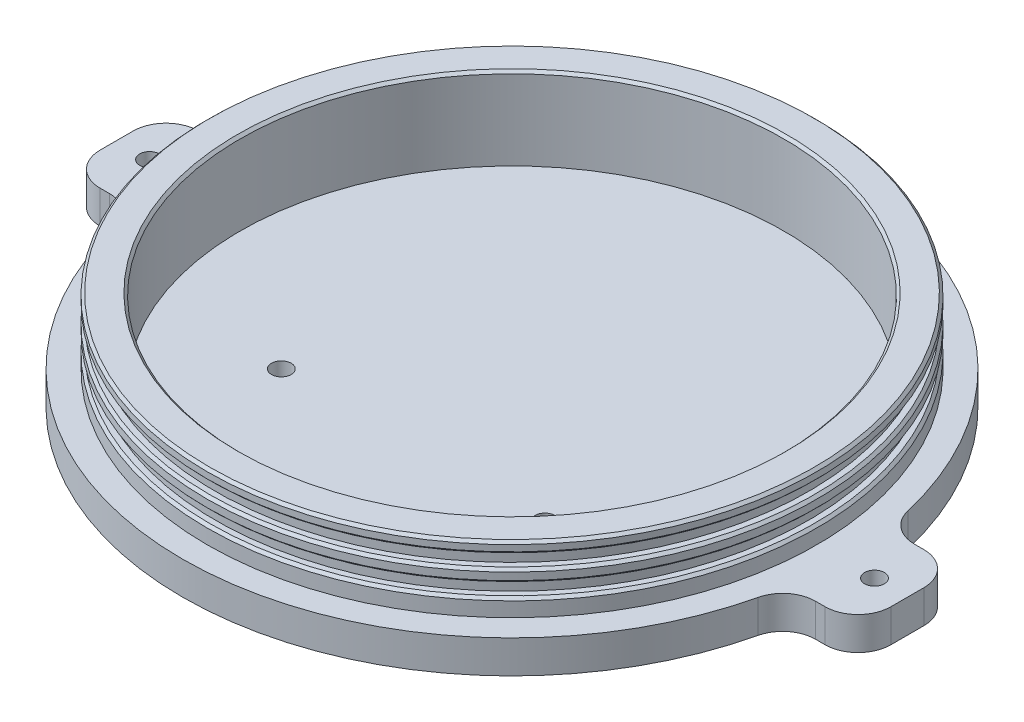
from build123d import *

# Parameters (mm, degrees)
SKETCH1_R                 = 63.5
EXTRUDE1_DEPTH            = 6.35
SKETCH2_R                 = 58.7375
SKETCH2_R_2               = 52.3875
EXTRUDE2_DEPTH            = 12.7
SKETCH3_W                 = 1.5875
SKETCH3_H                 = 2.38125
CHAMFER1_SIZE             = 0.5
EXTRUDE3_DEPTH            = 6.35
F_6_CLEARANCE_HOLE1_D     = 3.7973
F_6_CLEARANCE_HOLE1_DEPTH = 330.2
F_6_CLEARANCE_HOLE1_TIP   = 1.140824014
FILLET1_R                 = 6.35
F_6_CLEARANCE_HOLE2_D     = 3.7973
F_6_CLEARANCE_HOLE2_DEPTH = 25.4
F_6_CLEARANCE_HOLE2_TIP   = 1.140824014
SKETCH8_R                 = 52.3875
CUT_EXTRUDE1_DEPTH        = 3.175


with BuildPart() as part:
    # Sketch1 → Extrude1 (new body)
    with BuildSketch(Plane(origin=(0, 0, 0), x_dir=(1, 0, 0), z_dir=(0, 1, 0))):
        Circle(SKETCH1_R)
    extrude(amount=EXTRUDE1_DEPTH)

    # Sketch2 → Extrude2 (add)
    with BuildSketch(Plane(origin=(0, 6.35, 0), x_dir=(-1, 0, 0), z_dir=(0, 1, 0))):
        Circle(SKETCH2_R)
        Circle(SKETCH2_R_2, mode=Mode.SUBTRACT)
    extrude(amount=EXTRUDE2_DEPTH)

    # Sketch3 → Cut-Revolve1 (revolve, cut)
    with BuildSketch(Plane(origin=(0, 0, 0), x_dir=(0, 0, -1), z_dir=(1, 0, 0))):
        with Locations((-57.94375, 15.656558664)):
            Rectangle(SKETCH3_W, SKETCH3_H)
        with Locations((-57.94375, 10.842416167)):
            Rectangle(SKETCH3_W, SKETCH3_H)
    revolve(axis=Axis((0, 0, 0), (0, 1, 0)), mode=Mode.SUBTRACT)

    # Chamfer1
    chamfer1_edges = [part.edges().sort_by_distance(p)[0] for p in [
        (58.7375, 16.847183664, 0),
        (58.7375, 14.465933664, 0),
        (58.7375, 12.033041167, 0),
        (58.7375, 9.651791167, 0),
        (58.7375, 19.05, 0),
        (52.3875, 19.05, 0),
    ]]
    chamfer(chamfer1_edges, length=CHAMFER1_SIZE)

    # Sketch5 → Extrude3 (add)
    with BuildSketch(Plane.XZ):
        with BuildLine():
            Line((-69.85, 9.525), (69.85, 9.525))
            ThreePointArc((69.85, 9.525), (74.340128061, 7.665128061), (76.2, 3.175))
            Line((76.2, 3.175), (76.2, -3.175))
            ThreePointArc((76.2, -3.175), (74.340128061, -7.665128061), (69.85, -9.525))
            Line((69.85, -9.525), (-69.85, -9.525))
            ThreePointArc((-69.85, -9.525), (-74.340128061, -7.665128061), (-76.2, -3.175))
            Line((-76.2, -3.175), (-76.2, 3.175))
            ThreePointArc((-76.2, 3.175), (-74.340128061, 7.665128061), (-69.85, 9.525))
        make_face()
    extrude(amount=-EXTRUDE3_DEPTH)

    # #6 Clearance Hole1
    with Locations(Plane(origin=(-69.85, 0, 0), x_dir=(0, 0, -1), z_dir=(0, -1, 0))):
        with Locations((0, 0), (0, 139.7)):
            Hole(F_6_CLEARANCE_HOLE1_D / 2, depth=F_6_CLEARANCE_HOLE1_DEPTH)
            with Locations((0, 0, -(F_6_CLEARANCE_HOLE1_DEPTH + F_6_CLEARANCE_HOLE1_TIP / 2))):  # 118° drill point
                Cone(0, F_6_CLEARANCE_HOLE1_D / 2, F_6_CLEARANCE_HOLE1_TIP, mode=Mode.SUBTRACT)

    # Fillet1
    fillet1_edges = [part.edges().sort_by_distance(p)[0] for p in [
        (62.781560788, 3.175, -9.525),
        (-62.781560788, 3.175, -9.525),
        (-62.781560788, 3.175, 9.525),
        (62.781560788, 3.175, 9.525),
    ]]
    fillet(fillet1_edges, radius=FILLET1_R)

    # #6 Clearance Hole2
    with Locations(Plane(origin=(25.4, 0, 19.05), x_dir=(0, 0, -1), z_dir=(0, -1, 0))):
        with Locations((0, 0), (-19.05, 0), (-19.05, -50.8), (0, -50.8)):
            Hole(F_6_CLEARANCE_HOLE2_D / 2, depth=F_6_CLEARANCE_HOLE2_DEPTH)
            with Locations((0, 0, -(F_6_CLEARANCE_HOLE2_DEPTH + F_6_CLEARANCE_HOLE2_TIP / 2))):  # 118° drill point
                Cone(0, F_6_CLEARANCE_HOLE2_D / 2, F_6_CLEARANCE_HOLE2_TIP, mode=Mode.SUBTRACT)

    # Sketch8 → Cut-Extrude1 (cut)
    with BuildSketch(Plane(origin=(0, 6.35, 0), x_dir=(-1, 0, 0), z_dir=(0, 1, 0))):
        Circle(SKETCH8_R)
    extrude(amount=-CUT_EXTRUDE1_DEPTH, mode=Mode.SUBTRACT)


solid = part.part
